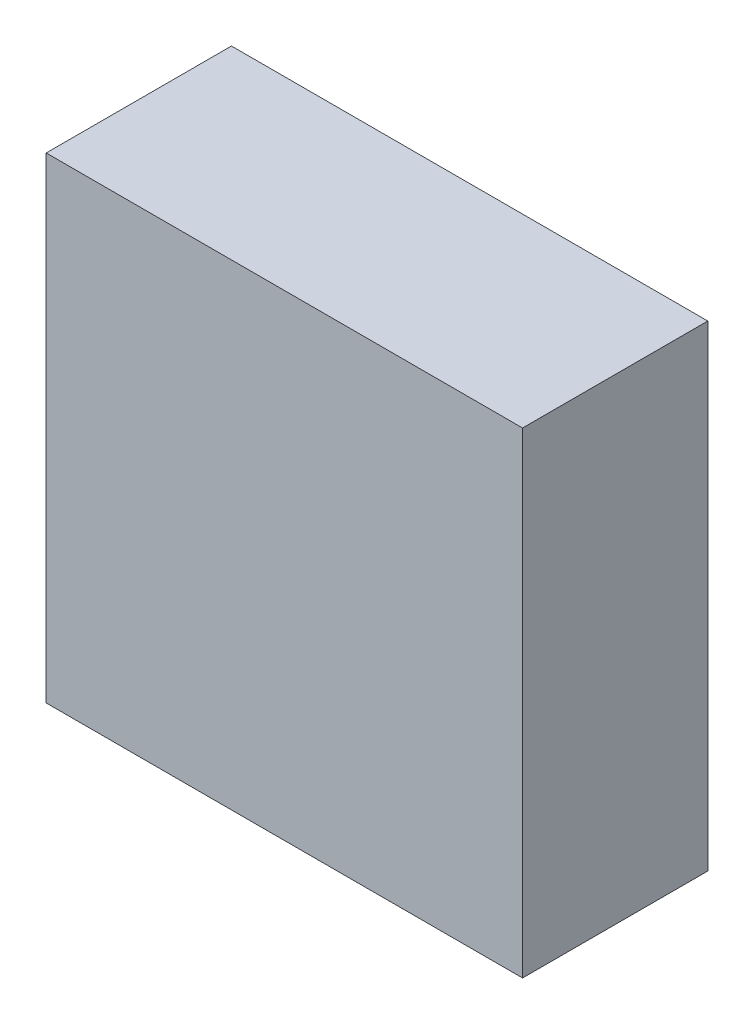
from build123d import *

# Parameters (mm, degrees)
SKICA1_W                = 90
SKICA1_H                = 90
P_IDAT_VYSUNUT_M1_DEPTH = 35


with BuildPart() as part:
    # Skica1 → Přidat vysunutím1 (new body)
    with BuildSketch(Plane.XY):
        with Locations((45, -45)):
            Rectangle(SKICA1_W, SKICA1_H)
    extrude(amount=P_IDAT_VYSUNUT_M1_DEPTH)


solid = part.part
